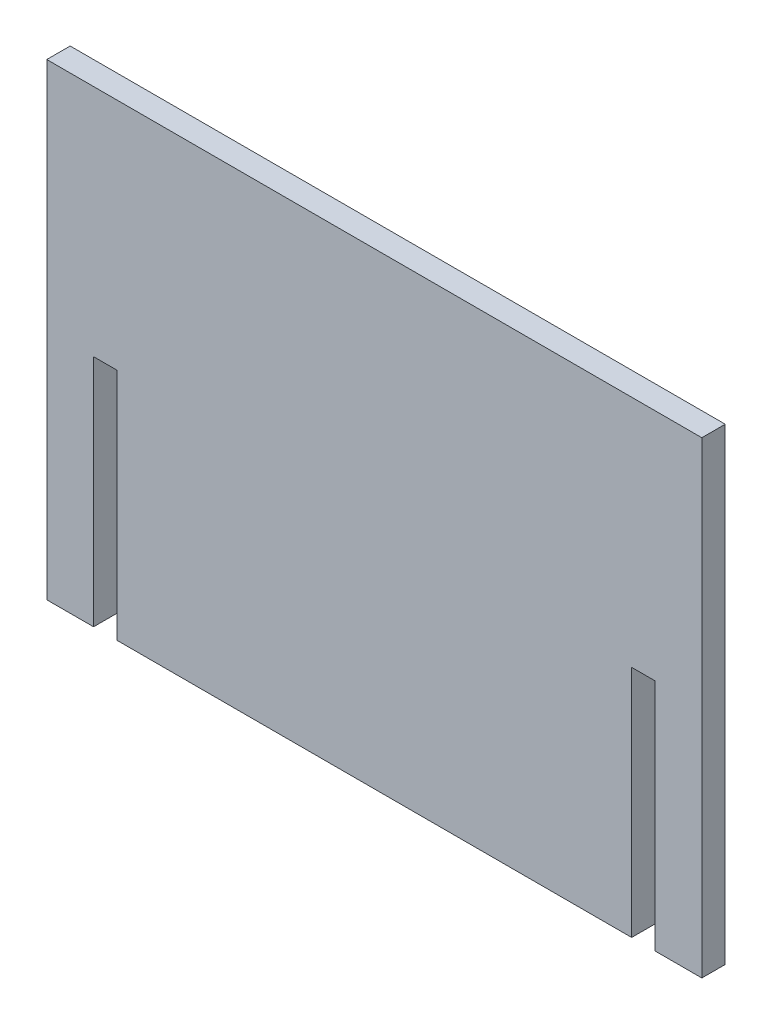
from build123d import *

# Parameters (mm, degrees)
BOSS_EXTRUDE1_DEPTH = 6.35


with BuildPart() as part:
    # Sketch1 → Boss-Extrude1 (new body, symmetric)
    with BuildSketch(Plane.XY):
        Polygon((1294.203955658, -24.179867224), (1649.803955658, -24.179867224), (1649.803955658, -278.179867224), (1624.403955658, -278.179867224), (1624.403955658, -151.179867224), (1611.703955658, -151.179867224), (1611.703955658, -278.179867224), (1332.303955658, -278.179867224), (1332.303955658, -151.179867224), (1319.603955658, -151.179867224), (1319.603955658, -278.179867224), (1294.203955658, -278.179867224), align=None)
    extrude(amount=BOSS_EXTRUDE1_DEPTH, both=True)


solid = part.part
